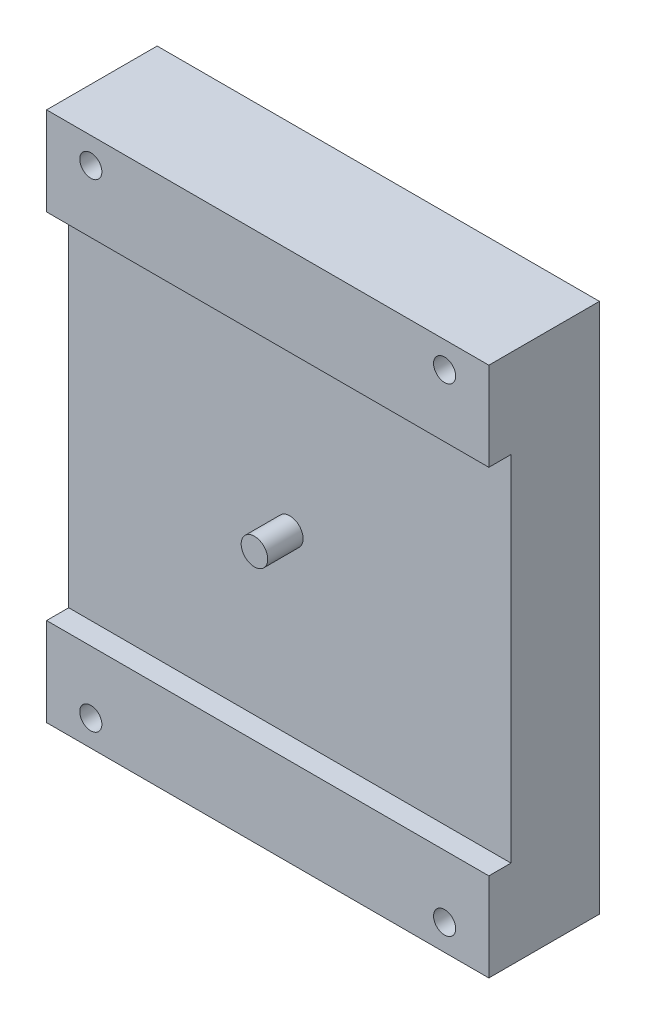
from build123d import *

# Parameters (mm, degrees)
SKIZZE1_W                       = 50
SKIZZE1_H                       = 60
SKIZZE1_R                       = 1.25
AUFSATZ_LINEAR_AUSTRAGEN1_DEPTH = 10
SKIZZE2_R                       = 1.5
AUFSATZ_LINEAR_AUSTRAGEN2_DEPTH = 4
SKIZZE3_W                       = 50
SKIZZE3_H                       = 10
SKIZZE3_R                       = 1.25
AUFSATZ_LINEAR_AUSTRAGEN3_DEPTH = 2.5


with BuildPart() as part:
    # Skizze1 → Aufsatz-Linear austragen1 (new body)
    with BuildSketch(Plane.XY):
        with Locations((-25, 30)):
            Rectangle(SKIZZE1_W, SKIZZE1_H)
        with Locations((-45, 57.05)):
            Circle(SKIZZE1_R, mode=Mode.SUBTRACT)
        with Locations((-5, 57.05)):
            Circle(SKIZZE1_R, mode=Mode.SUBTRACT)
        with Locations((-45, 2.95)):
            Circle(SKIZZE1_R, mode=Mode.SUBTRACT)
        with Locations((-5, 2.95)):
            Circle(SKIZZE1_R, mode=Mode.SUBTRACT)
    extrude(amount=AUFSATZ_LINEAR_AUSTRAGEN1_DEPTH)

    # Skizze2 → Aufsatz-Linear austragen2 (add)
    with BuildSketch(Plane.XY.offset(10)):
        with Locations((-25, 30)):
            Circle(SKIZZE2_R)
    extrude(amount=AUFSATZ_LINEAR_AUSTRAGEN2_DEPTH)

    # Skizze3 → Aufsatz-Linear austragen3 (add)
    with BuildSketch(Plane.XY.offset(10)):
        with Locations((-25, 55)):
            Rectangle(SKIZZE3_W, SKIZZE3_H)
        with Locations((-45, 57.05)):
            Circle(SKIZZE3_R, mode=Mode.SUBTRACT)
        with Locations((-5, 57.05)):
            Circle(SKIZZE3_R, mode=Mode.SUBTRACT)
        with Locations((-25, 5)):
            Rectangle(SKIZZE3_W, SKIZZE3_H)
        with Locations((-45, 2.95)):
            Circle(SKIZZE3_R, mode=Mode.SUBTRACT)
        with Locations((-5, 2.95)):
            Circle(SKIZZE3_R, mode=Mode.SUBTRACT)
    extrude(amount=AUFSATZ_LINEAR_AUSTRAGEN3_DEPTH)


solid = part.part
